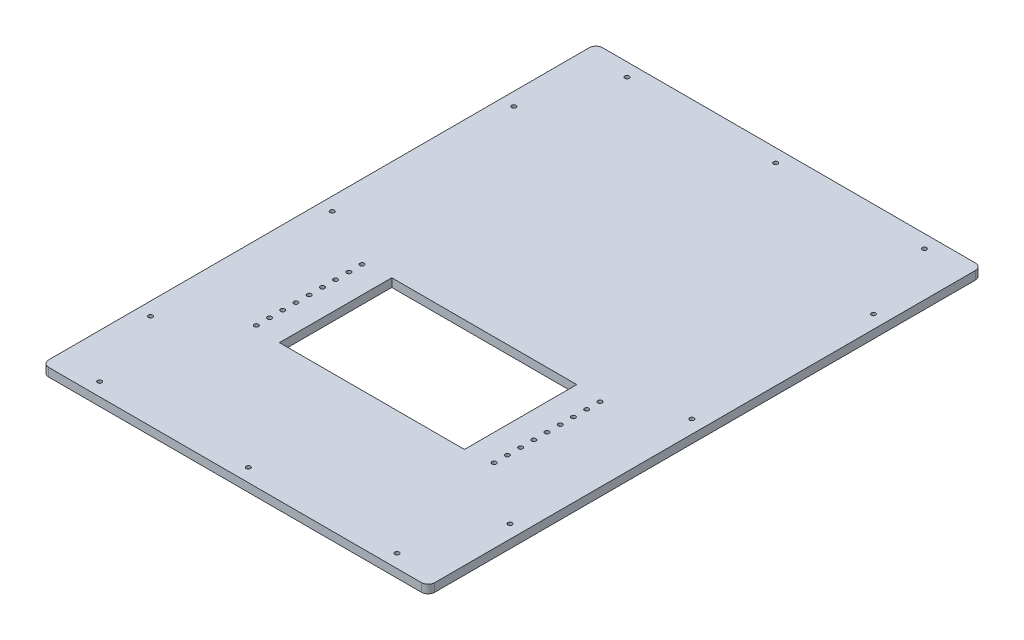
from build123d import *

# Parameters (mm, degrees)
SKETCH1_W                            = 584.2
SKETCH1_H                            = 838.2
LEXAN_BOSS_EXTRUDE1_DEPTH            = 12.7
HOUSING_NEST_HOLE_CUT_EXTRUDE1_REACH = 14.7
SKETCH5_W                            = 280
SKETCH5_H                            = 170
CUT_EXTRUDE7_REACH                   = 14.7
SKETCH6_R                            = 3.25
SKETCH9_R                            = 3.25
CUT_EXTRUDE6_DEPTH                   = 13.7
LPATTERN5_COUNT                      = 5
LPATTERN5_PITCH                      = 20
LPATTERN5_COL_COUNT                  = 5
LPATTERN5_COL_PITCH                  = 20
FILLET3_R                            = 10


with BuildPart() as part:
    # Sketch1 → Lexan Boss-Extrude1 (new body)
    with BuildSketch(Plane(origin=(0, 0, 0), x_dir=(1, 0, 0), z_dir=(0, 1, 0))):
        Rectangle(SKETCH1_W, SKETCH1_H)
    extrude(amount=LEXAN_BOSS_EXTRUDE1_DEPTH)

    # Sketch5 → Housing nest hole Cut-Extrude1 (cut, up to next)
    with BuildSketch(Plane.XZ, mode=Mode.PRIVATE) as housing_nest_hole_cut_extrude1_sk1:
        with Locations((0, 127)):
            Rectangle(SKETCH5_W, SKETCH5_H)
    housing_nest_hole_cut_extrude1_tool1 = extrude(housing_nest_hole_cut_extrude1_sk1.sketch, amount=-HOUSING_NEST_HOLE_CUT_EXTRUDE1_REACH, mode=Mode.PRIVATE) & part.part
    add(housing_nest_hole_cut_extrude1_tool1.solids().sort_by_distance((0, 0, 127))[0], mode=Mode.SUBTRACT)

    # Sketch6 → Cut-Extrude7 (cut, up to next)
    with BuildSketch(Plane.XZ, mode=Mode.PRIVATE) as cut_extrude7_sk1:
        with Locations((-272.1, 275)):
            Circle(SKETCH6_R)
    cut_extrude7_tool1 = extrude(cut_extrude7_sk1.sketch, amount=-CUT_EXTRUDE7_REACH, mode=Mode.PRIVATE) & part.part
    add(cut_extrude7_tool1.solids().sort_by_distance((-272.1, 0, 275))[0], mode=Mode.SUBTRACT)
    # Sketch6 → Cut-Extrude7 (cut, up to next)
    with BuildSketch(Plane.XZ, mode=Mode.PRIVATE) as cut_extrude7_sk2:
        with Locations((-272.1, 0)):
            Circle(SKETCH6_R)
    cut_extrude7_tool2 = extrude(cut_extrude7_sk2.sketch, amount=-CUT_EXTRUDE7_REACH, mode=Mode.PRIVATE) & part.part
    add(cut_extrude7_tool2.solids().sort_by_distance((-272.1, 0, 0))[0], mode=Mode.SUBTRACT)
    # Sketch6 → Cut-Extrude7 (cut, up to next)
    with BuildSketch(Plane.XZ, mode=Mode.PRIVATE) as cut_extrude7_sk3:
        with Locations((-272.1, -275)):
            Circle(SKETCH6_R)
    cut_extrude7_tool3 = extrude(cut_extrude7_sk3.sketch, amount=-CUT_EXTRUDE7_REACH, mode=Mode.PRIVATE) & part.part
    add(cut_extrude7_tool3.solids().sort_by_distance((-272.1, 0, -275))[0], mode=Mode.SUBTRACT)
    # Sketch6 → Cut-Extrude7 (cut, up to next)
    with BuildSketch(Plane.XZ, mode=Mode.PRIVATE) as cut_extrude7_sk4:
        with Locations((272.1, -275)):
            Circle(SKETCH6_R)
    cut_extrude7_tool4 = extrude(cut_extrude7_sk4.sketch, amount=-CUT_EXTRUDE7_REACH, mode=Mode.PRIVATE) & part.part
    add(cut_extrude7_tool4.solids().sort_by_distance((272.1, 0, -275))[0], mode=Mode.SUBTRACT)
    # Sketch6 → Cut-Extrude7 (cut, up to next)
    with BuildSketch(Plane.XZ, mode=Mode.PRIVATE) as cut_extrude7_sk5:
        with Locations((272.1, 0)):
            Circle(SKETCH6_R)
    cut_extrude7_tool5 = extrude(cut_extrude7_sk5.sketch, amount=-CUT_EXTRUDE7_REACH, mode=Mode.PRIVATE) & part.part
    add(cut_extrude7_tool5.solids().sort_by_distance((272.1, 0, 0))[0], mode=Mode.SUBTRACT)
    # Sketch6 → Cut-Extrude7 (cut, up to next)
    with BuildSketch(Plane.XZ, mode=Mode.PRIVATE) as cut_extrude7_sk6:
        with Locations((272.1, 275)):
            Circle(SKETCH6_R)
    cut_extrude7_tool6 = extrude(cut_extrude7_sk6.sketch, amount=-CUT_EXTRUDE7_REACH, mode=Mode.PRIVATE) & part.part
    add(cut_extrude7_tool6.solids().sort_by_distance((272.1, 0, 275))[0], mode=Mode.SUBTRACT)
    # Sketch6 → Cut-Extrude7 (cut, up to next)
    with BuildSketch(Plane.XZ, mode=Mode.PRIVATE) as cut_extrude7_sk7:
        with Locations((-225, 399.1)):
            Circle(SKETCH6_R)
    cut_extrude7_tool7 = extrude(cut_extrude7_sk7.sketch, amount=-CUT_EXTRUDE7_REACH, mode=Mode.PRIVATE) & part.part
    add(cut_extrude7_tool7.solids().sort_by_distance((-225, 0, 399.1))[0], mode=Mode.SUBTRACT)
    # Sketch6 → Cut-Extrude7 (cut, up to next)
    with BuildSketch(Plane.XZ, mode=Mode.PRIVATE) as cut_extrude7_sk8:
        with Locations((0, 399.1)):
            Circle(SKETCH6_R)
    cut_extrude7_tool8 = extrude(cut_extrude7_sk8.sketch, amount=-CUT_EXTRUDE7_REACH, mode=Mode.PRIVATE) & part.part
    add(cut_extrude7_tool8.solids().sort_by_distance((0, 0, 399.1))[0], mode=Mode.SUBTRACT)
    # Sketch6 → Cut-Extrude7 (cut, up to next)
    with BuildSketch(Plane.XZ, mode=Mode.PRIVATE) as cut_extrude7_sk9:
        with Locations((225, 399.1)):
            Circle(SKETCH6_R)
    cut_extrude7_tool9 = extrude(cut_extrude7_sk9.sketch, amount=-CUT_EXTRUDE7_REACH, mode=Mode.PRIVATE) & part.part
    add(cut_extrude7_tool9.solids().sort_by_distance((225, 0, 399.1))[0], mode=Mode.SUBTRACT)
    # Sketch6 → Cut-Extrude7 (cut, up to next)
    with BuildSketch(Plane.XZ, mode=Mode.PRIVATE) as cut_extrude7_sk10:
        with Locations((225, -399.1)):
            Circle(SKETCH6_R)
    cut_extrude7_tool10 = extrude(cut_extrude7_sk10.sketch, amount=-CUT_EXTRUDE7_REACH, mode=Mode.PRIVATE) & part.part
    add(cut_extrude7_tool10.solids().sort_by_distance((225, 0, -399.1))[0], mode=Mode.SUBTRACT)
    # Sketch6 → Cut-Extrude7 (cut, up to next)
    with BuildSketch(Plane.XZ, mode=Mode.PRIVATE) as cut_extrude7_sk11:
        with Locations((0, -399.1)):
            Circle(SKETCH6_R)
    cut_extrude7_tool11 = extrude(cut_extrude7_sk11.sketch, amount=-CUT_EXTRUDE7_REACH, mode=Mode.PRIVATE) & part.part
    add(cut_extrude7_tool11.solids().sort_by_distance((0, 0, -399.1))[0], mode=Mode.SUBTRACT)
    # Sketch6 → Cut-Extrude7 (cut, up to next)
    with BuildSketch(Plane.XZ, mode=Mode.PRIVATE) as cut_extrude7_sk12:
        with Locations((-225, -399.1)):
            Circle(SKETCH6_R)
    cut_extrude7_tool12 = extrude(cut_extrude7_sk12.sketch, amount=-CUT_EXTRUDE7_REACH, mode=Mode.PRIVATE) & part.part
    add(cut_extrude7_tool12.solids().sort_by_distance((-225, 0, -399.1))[0], mode=Mode.SUBTRACT)

    # Sketch9 → Cut-Extrude6 (cut, through all)
    with BuildSketch(Plane(origin=(0, 12.7, 0), x_dir=(1, 0, 0), z_dir=(0, 1, 0))):
        with Locations((-180, -127)):
            Circle(SKETCH9_R)
        with Locations((180, -127)):
            Circle(SKETCH9_R)
    cut_extrude6 = extrude(amount=-CUT_EXTRUDE6_DEPTH, mode=Mode.SUBTRACT)

    # LPattern5: Cut-Extrude6 ×5
    with Locations(*[(0, 0, i * LPATTERN5_PITCH) for i in range(1, LPATTERN5_COUNT)]):
        add(cut_extrude6, mode=Mode.SUBTRACT)

    # LPattern5 col: Cut-Extrude6 ×5
    with Locations(*[(0, 0, -i * LPATTERN5_COL_PITCH) for i in range(1, LPATTERN5_COL_COUNT)]):
        add(cut_extrude6, mode=Mode.SUBTRACT)

    # Fillet3
    fillet3_edges = [part.edges().sort_by_distance(p)[0] for p in [
        (292.1, 6.35, 419.1),
        (-292.1, 6.35, 419.1),
        (-292.1, 6.35, -419.1),
        (292.1, 6.35, -419.1),
    ]]
    fillet(fillet3_edges, radius=FILLET3_R)


solid = part.part
